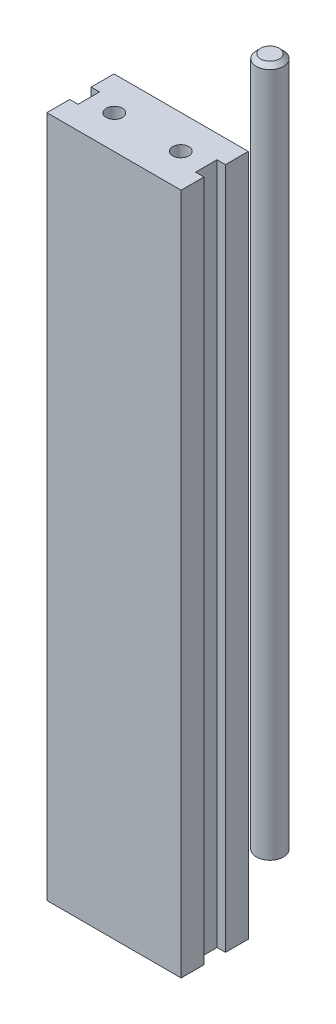
from build123d import *

# Parameters (mm, degrees)
SKETCH1_W                = 40
SKETCH1_H                = 20
BOSS_EXTRUDE1_DEPTH      = 101.6
SKETCH2_W                = 2.5
SKETCH2_H                = 6.4
CUT_EXTRUDE1_DEPTH       = 204.2
SKETCH3_R                = 2.4
CUT_EXTRUDE2_DEPTH       = 204.2
SKETCH4_R                = 4.05
BOSS_EXTRUDE2_DEPTH      = 2
BOSS_EXTRUDE2_DEPTH_BACK = 203.2
CHAMFER1_SIZE            = 1.27


with BuildPart() as part:
    # Sketch1 → Boss-Extrude1 (new body, symmetric)
    with BuildSketch(Plane(origin=(0, 0, 0), x_dir=(1, 0, 0), z_dir=(0, 1, 0))):
        Rectangle(SKETCH1_W, SKETCH1_H)
    extrude(amount=BOSS_EXTRUDE1_DEPTH, both=True)

    # Sketch2 → Cut-Extrude1 (cut, through all)
    with BuildSketch(Plane(origin=(0, 101.6, 0), x_dir=(1, 0, 0), z_dir=(0, 1, 0))):
        with Locations((-18.75, 0)):
            Rectangle(SKETCH2_W, SKETCH2_H)
        with Locations((18.75, 0)):
            Rectangle(SKETCH2_W, SKETCH2_H)
    extrude(amount=-CUT_EXTRUDE1_DEPTH, mode=Mode.SUBTRACT)

    # Sketch3 → Cut-Extrude2 (cut, through all)
    with BuildSketch(Plane(origin=(0, 101.6, 0), x_dir=(1, 0, 0), z_dir=(0, 1, 0))):
        with Locations((-9.9, 0)):
            Circle(SKETCH3_R)
        with Locations((9.9, 0)):
            Circle(SKETCH3_R)
    extrude(amount=-CUT_EXTRUDE2_DEPTH, mode=Mode.SUBTRACT)


with BuildPart() as body_2:
    # Sketch4 → Boss-Extrude2 (new body, two sides)
    with BuildSketch(Plane(origin=(0, 101.6, 0), x_dir=(1, 0, 0), z_dir=(0, 1, 0))) as boss_extrude2_sk:
        with Locations((0, 36.45)):
            Circle(SKETCH4_R)
    extrude(amount=BOSS_EXTRUDE2_DEPTH)
    extrude(boss_extrude2_sk.sketch, amount=-BOSS_EXTRUDE2_DEPTH_BACK)

    # Chamfer1
    chamfer1_edges = [body_2.edges().sort_by_distance(p)[0] for p in [
        (-4.05, 103.6, -36.45),
    ]]
    chamfer(chamfer1_edges, length=CHAMFER1_SIZE)


solid = Compound([part.part, body_2.part])
